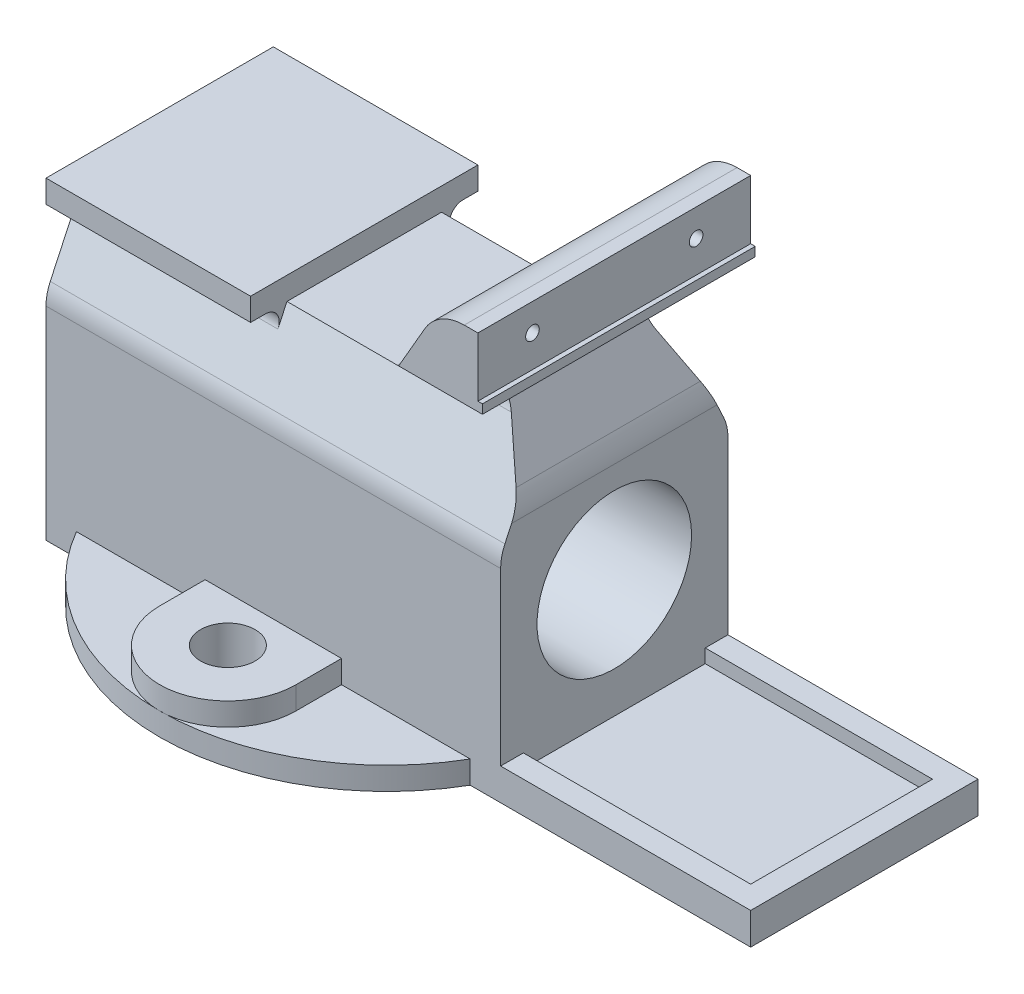
from build123d import *

# Parameters (mm, degrees)
SKETCH17_R          = 50
BOSS_EXTRUDE9_DEPTH = 5
BOSS_EXTRUDE1_DEPTH = 5
SKETCH3_R           = 6
CUT_EXTRUDE1_DEPTH  = 11
BOSS_EXTRUDE3_DEPTH = 50
BOSS_EXTRUDE7_DEPTH = 45
SKETCH6_W           = 55
SKETCH6_H           = 7
BOSS_EXTRUDE4_DEPTH = 50
BOSS_EXTRUDE5_DEPTH = 30
CUT_EXTRUDE2_DEPTH  = 81
CUT_EXTRUDE4_REACH  = 102
SKETCH12_W          = 60
SKETCH12_H          = 2
BOSS_EXTRUDE6_DEPTH = 1
SKETCH14_R          = 17
CUT_EXTRUDE7_DEPTH  = 101
SKETCH15_R          = 1.5
CUT_EXTRUDE8_DEPTH  = 5
SKETCH18_W          = 50
SKETCH18_H          = 40
CUT_EXTRUDE9_DEPTH  = 3
FILLET1_R           = 10


with BuildPart() as part:
    # Sketch17 → Boss-Extrude9 (new body)
    with BuildSketch(Plane(origin=(0, 0, 0), x_dir=(1, 0, 0), z_dir=(0, 1, 0))):
        with Locations(Location((0, 0, 0), (0, 0, 270))):  # turned: the seam where the file's is
            Circle(SKETCH17_R)
    extrude(amount=BOSS_EXTRUDE9_DEPTH)

    # Sketch2 → Boss-Extrude1 (add)
    with BuildSketch(Plane.XZ.offset(-5)):
        with BuildLine():
            Line((-15, -35), (-15, 35))
            ThreePointArc((-15, 35), (0, 50), (15, 35))
            Line((15, 35), (15, -35))
            ThreePointArc((15, -35), (0, -50), (-15, -35))
        make_face()
    extrude(amount=-BOSS_EXTRUDE1_DEPTH)

    # Sketch3 → Cut-Extrude1 (cut, through all)
    with BuildSketch(Plane(origin=(0, 10, 0), x_dir=(1, 0, 0), z_dir=(0, 1, 0))):
        with Locations(Location((0, 35, 0), (0, 0, 270))):  # turned: the seam where the file's is
            Circle(SKETCH3_R)
        with Locations(Location((0, -35, 0), (0, 0, 270))):  # turned: the seam where the file's is
            Circle(SKETCH3_R)
    extrude(amount=-CUT_EXTRUDE1_DEPTH, mode=Mode.SUBTRACT)

    # Sketch5 → Boss-Extrude3 (add, symmetric)
    with BuildSketch(Plane(origin=(0, 0, 0), x_dir=(0, 0, -1), z_dir=(1, 0, 0))):
        with BuildLine():
            Line((17, 64), (-17, 64))
            Line((-17, 64), (-24.06307787, 48.853180627))
            ThreePointArc((-24.06307787, 48.853180627), (-24.762960071, 46.791394149), (-25, 44.626998009))
            Line((-25, 44.626998009), (-25, 0))
            Line((-25, 0), (25, 0))
            Line((25, 0), (25, 44.626998009))
            ThreePointArc((25, 44.626998009), (24.762960071, 46.791394149), (24.06307787, 48.853180627))
            Line((24.06307787, 48.853180627), (17, 64))
        make_face()
    extrude(amount=BOSS_EXTRUDE3_DEPTH, both=True)

    # Sketch4 → Boss-Extrude7 (add)
    with BuildSketch(Plane(origin=(-50, 0, 0), x_dir=(0, 0, -1), z_dir=(1, 0, 0))):
        with BuildLine():
            Line((-17, 64), (-18.99013337, 59.732145215))
            ThreePointArc((-18.99013337, 59.732145215), (-19.178882394, 62.611898825), (-21.709056731, 64))
            Line((-21.709056731, 64), (-25, 64))
            Line((-25, 64), (-25, 69))
            Line((-25, 69), (25, 69))
            Line((25, 69), (25, 64))
            Line((25, 64), (21.709056731, 64))
            ThreePointArc((21.709056731, 64), (19.178882394, 62.611898825), (18.99013337, 59.732145215))
            Line((18.99013337, 59.732145215), (17, 64))
            Line((17, 64), (-17, 64))
        make_face()
    extrude(amount=BOSS_EXTRUDE7_DEPTH)

    # Sketch6 → Boss-Extrude4 (add)
    with BuildSketch(Plane.XY.offset(25)):
        with Locations((77.5, 3.5)):
            Rectangle(SKETCH6_W, SKETCH6_H)
    extrude(amount=-BOSS_EXTRUDE4_DEPTH)

    # Sketch7 → Boss-Extrude5 (add, symmetric)
    with BuildSketch(Plane.XY):
        with BuildLine():
            Line((50, 64), (50, 92))
            Line((50, 92), (47, 92))
            ThreePointArc((47, 92), (42, 90.660254038), (38.339745962, 87))
            Line((38.339745962, 87), (25.060689771, 64))
            Line((25.060689771, 64), (50, 64))
        make_face()
    extrude(amount=BOSS_EXTRUDE5_DEPTH, both=True)

    # Sketch8 → Cut-Extrude2 (cut, through all)
    with BuildSketch(Plane.XY.offset(30)):
        with BuildLine():
            Line((50, 52), (50, 77))
            Line((50, 77), (45.773502692, 77))
            ThreePointArc((45.773502692, 77), (41.443375673, 74.5), (41.443375673, 69.5))
            Line((41.443375673, 69.5), (48.660254038, 57))
            ThreePointArc((48.660254038, 57), (49.659258263, 54.588190451), (50, 52))
        make_face()
    extrude(amount=-CUT_EXTRUDE2_DEPTH, mode=Mode.SUBTRACT)

    # Sketch10 → Cut-Extrude4 (cut, up to next)
    with BuildSketch(Plane(origin=(50, 0, 0), x_dir=(0, 0, -1), z_dir=(1, 0, 0)), mode=Mode.PRIVATE) as cut_extrude4_sk1:
        with BuildLine():
            Line((30, 77), (30, 36.121410033))
            Line((30, 36.121410033), (15.858955464, 66.446977905))
            ThreePointArc((15.858955464, 66.446977905), (16.325670644, 73.56767554), (22.581972002, 77))
            Line((22.581972002, 77), (30, 77))
        make_face()
    cut_extrude4_tool1 = extrude(cut_extrude4_sk1.sketch, amount=-CUT_EXTRUDE4_REACH, mode=Mode.PRIVATE) & part.part
    add(cut_extrude4_tool1.solids().sort_by_distance((50, 62.410473, -24.403719))[0], mode=Mode.SUBTRACT)
    # Sketch10 → Cut-Extrude4 (cut, up to next)
    with BuildSketch(Plane(origin=(50, 0, 0), x_dir=(0, 0, -1), z_dir=(1, 0, 0)), mode=Mode.PRIVATE) as cut_extrude4_sk2:
        with BuildLine():
            Line((-30, 77), (-22.581972002, 77))
            ThreePointArc((-22.581972002, 77), (-16.325670644, 73.56767554), (-15.858955464, 66.446977905))
            Line((-15.858955464, 66.446977905), (-30, 36.121410033))
            Line((-30, 36.121410033), (-30, 77))
        make_face()
    cut_extrude4_tool2 = extrude(cut_extrude4_sk2.sketch, amount=-CUT_EXTRUDE4_REACH, mode=Mode.PRIVATE) & part.part
    add(cut_extrude4_tool2.solids().sort_by_distance((50, 62.410473, 24.403719))[0], mode=Mode.SUBTRACT)

    # Sketch12 → Boss-Extrude6 (add)
    with BuildSketch(Plane(origin=(50, 0, 0), x_dir=(0, 0, -1), z_dir=(1, 0, 0))):
        with Locations((0, 78)):
            Rectangle(SKETCH12_W, SKETCH12_H)
    extrude(amount=BOSS_EXTRUDE6_DEPTH)

    # Sketch14 → Cut-Extrude7 (cut, through all)
    with BuildSketch(Plane(origin=(50, 0, 0), x_dir=(0, 0, -1), z_dir=(1, 0, 0))):
        with Locations((0, 30)):
            Circle(SKETCH14_R)
    extrude(amount=-CUT_EXTRUDE7_DEPTH, mode=Mode.SUBTRACT)

    # Sketch15 → Cut-Extrude8 (cut)
    with BuildSketch(Plane(origin=(50, 0, 0), x_dir=(0, 0, -1), z_dir=(1, 0, 0))):
        with Locations((-18, 86)):
            Circle(SKETCH15_R)
        with Locations(Location((18, 86, 0), (0, 0, 180))):  # turned: the seam where the file's is
            Circle(SKETCH15_R)
    extrude(amount=-CUT_EXTRUDE8_DEPTH, mode=Mode.SUBTRACT)

    # Sketch18 → Cut-Extrude9 (cut)
    with BuildSketch(Plane(origin=(0, 7, 0), x_dir=(1, 0, 0), z_dir=(0, 1, 0))):
        with Locations((75, 0)):
            Rectangle(SKETCH18_W, SKETCH18_H)
    extrude(amount=-CUT_EXTRUDE9_DEPTH, mode=Mode.SUBTRACT)

    # Fillet1
    fillet1_edges = [part.edges().sort_by_distance(p)[0] for p in [
        (25.060689771, 64, 0),
    ]]
    fillet(fillet1_edges, radius=FILLET1_R)


solid = part.part
